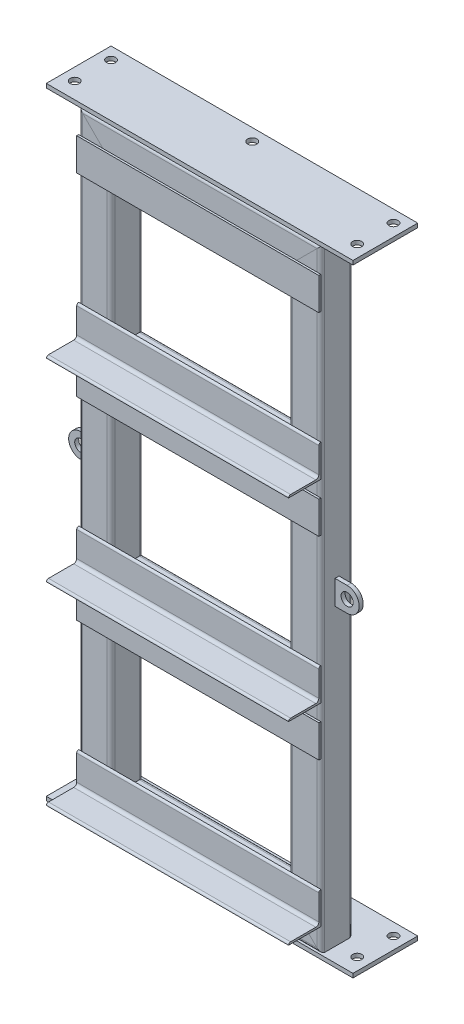
from build123d import *

# Parameters (mm, degrees)
STRUCTURAL_MEMBER1_DEPTH                = 951.321024484
STRUCTURAL_MEMBER1_DEPTH_BACK           = 36.921024484
STRUCTURAL_MEMBER1_2_DEPTH              = 404.042048969
STRUCTURAL_MEMBER1_3_DEPTH              = 988.242048969
STRUCTURAL_MEMBER1_4_DEPTH              = 404.042048969
STRUCTURAL_MEMBER1_5_DEPTH              = 332.2
STRUCTURAL_MEMBER1_6_DEPTH              = 332.2
SKETCH12_W                              = 482.6
SKETCH12_H                              = 101.865039743
BOSS_EXTRUDE1_DEPTH                     = 6.35
F_9_16_0_5625_DIAMETER_HOLE1_AT_2_COUNT = 2
F_9_16_0_5625_DIAMETER_HOLE1_AT_2_PITCH = 57.15
F_9_16_0_5625_DIAMETER_HOLE1_AT_3_COUNT = 2
F_9_16_0_5625_DIAMETER_HOLE1_AT_3_PITCH = 448.15886971
F_9_16_0_5625_DIAMETER_HOLE1_AT_4_COUNT = 2
F_9_16_0_5625_DIAMETER_HOLE1_AT_4_PITCH = 444.5
F_9_16_0_5625_DIAMETER_HOLE1_AT_5_COUNT = 2
F_9_16_0_5625_DIAMETER_HOLE1_AT_5_PITCH = 222.25
STRUCTURAL_MEMBER2_DEPTH                = 381
SKETCH142_W                             = 3.175
SKETCH142_H                             = 50.8
BOSS_EXTRUDE2_DEPTH                     = 381
LPATTERN1_COUNT                         = 3
LPATTERN1_PITCH                         = 304.8
SKETCH144_R                             = 9.525
BOSS_EXTRUDE3_DEPTH                     = 3.175


with BuildPart() as part:
    # Sketch11 → Structural Member1 (new, two sides)
    with BuildSketch(Plane(origin=(-165.1, -457.2, 0), x_dir=(-1, 0, 0), z_dir=(0, 1, 0))) as structural_member1_sk:
        with BuildLine():
            Line((-19.304, -25.4), (19.304, -25.4))
            ThreePointArc((19.304, -25.4), (23.614522938, -23.614522938), (25.4, -19.304))
            Line((25.4, -19.304), (25.4, 19.304))
            ThreePointArc((25.4, 19.304), (23.614522938, 23.614522938), (19.304, 25.4))
            Line((19.304, 25.4), (-19.304, 25.4))
            ThreePointArc((-19.304, 25.4), (-23.614522938, 23.614522938), (-25.4, 19.304))
            Line((-25.4, 19.304), (-25.4, -19.304))
            ThreePointArc((-25.4, -19.304), (-23.614522938, -23.614522938), (-19.304, -25.4))
        make_face()
        with BuildLine():
            Line((-19.304, -22.352), (19.304, -22.352))
            ThreePointArc((19.304, -22.352), (21.459261469, -21.459261469), (22.352, -19.304))
            Line((22.352, -19.304), (22.352, 19.304))
            ThreePointArc((22.352, 19.304), (21.459261469, 21.459261469), (19.304, 22.352))
            Line((19.304, 22.352), (-19.304, 22.352))
            ThreePointArc((-19.304, 22.352), (-21.459261469, 21.459261469), (-22.352, 19.304))
            Line((-22.352, 19.304), (-22.352, -19.304))
            ThreePointArc((-22.352, -19.304), (-21.459261469, -21.459261469), (-19.304, -22.352))
        make_face(mode=Mode.SUBTRACT)
    extrude(amount=STRUCTURAL_MEMBER1_DEPTH)
    extrude(structural_member1_sk.sketch, amount=-STRUCTURAL_MEMBER1_DEPTH_BACK)

    # Structural Member1 mitre 1
    split(bisect_by=Plane(origin=(-165.1, -457.2, 0), x_dir=(-0.707106781, -0.707106781, 0), z_dir=(-0.707106781, 0.707106781, 0)), keep=Keep.TOP)

    # Structural Member1 mitre 2
    split(bisect_by=Plane(origin=(-165.1, 457.2, 0), x_dir=(0.707106781, -0.707106781, 0), z_dir=(-0.707106781, -0.707106781, 0)), keep=Keep.TOP)


with BuildPart() as body_2:
    # Sketch11 on segment 2 (carried to segment 2) → Structural Member1 2 (new body)
    with BuildSketch(Plane(origin=(-202.021024484, 457.2, 0), x_dir=(0, 1, 0), z_dir=(1, 0, 0))):
        with BuildLine():
            Line((-19.304, -25.4), (19.304, -25.4))
            ThreePointArc((19.304, -25.4), (23.614522938, -23.614522938), (25.4, -19.304))
            Line((25.4, -19.304), (25.4, 19.304))
            ThreePointArc((25.4, 19.304), (23.614522938, 23.614522938), (19.304, 25.4))
            Line((19.304, 25.4), (-19.304, 25.4))
            ThreePointArc((-19.304, 25.4), (-23.614522938, 23.614522938), (-25.4, 19.304))
            Line((-25.4, 19.304), (-25.4, -19.304))
            ThreePointArc((-25.4, -19.304), (-23.614522938, -23.614522938), (-19.304, -25.4))
        make_face()
        with BuildLine():
            Line((-19.304, -22.352), (19.304, -22.352))
            ThreePointArc((19.304, -22.352), (21.459261469, -21.459261469), (22.352, -19.304))
            Line((22.352, -19.304), (22.352, 19.304))
            ThreePointArc((22.352, 19.304), (21.459261469, 21.459261469), (19.304, 22.352))
            Line((19.304, 22.352), (-19.304, 22.352))
            ThreePointArc((-19.304, 22.352), (-21.459261469, 21.459261469), (-22.352, 19.304))
            Line((-22.352, 19.304), (-22.352, -19.304))
            ThreePointArc((-22.352, -19.304), (-21.459261469, -21.459261469), (-19.304, -22.352))
        make_face(mode=Mode.SUBTRACT)
    extrude(amount=STRUCTURAL_MEMBER1_2_DEPTH)

    # Structural Member1 2 mitre 1
    split(bisect_by=Plane(origin=(165.1, 457.2, 0), x_dir=(-0.707106781, -0.707106781, 0), z_dir=(-0.707106781, 0.707106781, 0)), keep=Keep.TOP)

    # Structural Member1 2 mitre 2
    split(bisect_by=Plane(origin=(-165.1, 457.2, 0), x_dir=(-0.707106781, 0.707106781, 0), z_dir=(0.707106781, 0.707106781, 0)), keep=Keep.TOP)


with BuildPart() as body_3:
    # Sketch11 on segment 3 (carried to segment 3) → Structural Member1 3 (new body)
    with BuildSketch(Plane(origin=(165.1, 494.121024484, 0), x_dir=(1, 0, 0), z_dir=(0, -1, 0))):
        with BuildLine():
            Line((-19.304, -25.4), (19.304, -25.4))
            ThreePointArc((19.304, -25.4), (23.614522938, -23.614522938), (25.4, -19.304))
            Line((25.4, -19.304), (25.4, 19.304))
            ThreePointArc((25.4, 19.304), (23.614522938, 23.614522938), (19.304, 25.4))
            Line((19.304, 25.4), (-19.304, 25.4))
            ThreePointArc((-19.304, 25.4), (-23.614522938, 23.614522938), (-25.4, 19.304))
            Line((-25.4, 19.304), (-25.4, -19.304))
            ThreePointArc((-25.4, -19.304), (-23.614522938, -23.614522938), (-19.304, -25.4))
        make_face()
        with BuildLine():
            Line((-19.304, -22.352), (19.304, -22.352))
            ThreePointArc((19.304, -22.352), (21.459261469, -21.459261469), (22.352, -19.304))
            Line((22.352, -19.304), (22.352, 19.304))
            ThreePointArc((22.352, 19.304), (21.459261469, 21.459261469), (19.304, 22.352))
            Line((19.304, 22.352), (-19.304, 22.352))
            ThreePointArc((-19.304, 22.352), (-21.459261469, 21.459261469), (-22.352, 19.304))
            Line((-22.352, 19.304), (-22.352, -19.304))
            ThreePointArc((-22.352, -19.304), (-21.459261469, -21.459261469), (-19.304, -22.352))
        make_face(mode=Mode.SUBTRACT)
    extrude(amount=STRUCTURAL_MEMBER1_3_DEPTH)

    # Structural Member1 3 mitre 1
    split(bisect_by=Plane(origin=(165.1, -457.2, 0), x_dir=(-0.707106781, 0.707106781, 0), z_dir=(0.707106781, 0.707106781, 0)), keep=Keep.TOP)

    # Structural Member1 3 mitre 2
    split(bisect_by=Plane(origin=(165.1, 457.2, 0), x_dir=(0.707106781, 0.707106781, 0), z_dir=(0.707106781, -0.707106781, 0)), keep=Keep.TOP)


with BuildPart() as body_4:
    # Sketch11 on segment 4 (carried to segment 4) → Structural Member1 4 (new body)
    with BuildSketch(Plane(origin=(202.021024484, -457.2, 0), x_dir=(0, -1, 0), z_dir=(-1, 0, 0))):
        with BuildLine():
            Line((-19.304, -25.4), (19.304, -25.4))
            ThreePointArc((19.304, -25.4), (23.614522938, -23.614522938), (25.4, -19.304))
            Line((25.4, -19.304), (25.4, 19.304))
            ThreePointArc((25.4, 19.304), (23.614522938, 23.614522938), (19.304, 25.4))
            Line((19.304, 25.4), (-19.304, 25.4))
            ThreePointArc((-19.304, 25.4), (-23.614522938, 23.614522938), (-25.4, 19.304))
            Line((-25.4, 19.304), (-25.4, -19.304))
            ThreePointArc((-25.4, -19.304), (-23.614522938, -23.614522938), (-19.304, -25.4))
        make_face()
        with BuildLine():
            Line((-19.304, -22.352), (19.304, -22.352))
            ThreePointArc((19.304, -22.352), (21.459261469, -21.459261469), (22.352, -19.304))
            Line((22.352, -19.304), (22.352, 19.304))
            ThreePointArc((22.352, 19.304), (21.459261469, 21.459261469), (19.304, 22.352))
            Line((19.304, 22.352), (-19.304, 22.352))
            ThreePointArc((-19.304, 22.352), (-21.459261469, 21.459261469), (-22.352, 19.304))
            Line((-22.352, 19.304), (-22.352, -19.304))
            ThreePointArc((-22.352, -19.304), (-21.459261469, -21.459261469), (-19.304, -22.352))
        make_face(mode=Mode.SUBTRACT)
    extrude(amount=STRUCTURAL_MEMBER1_4_DEPTH)

    # Structural Member1 4 mitre 1
    split(bisect_by=Plane(origin=(165.1, -457.2, 0), x_dir=(0.707106781, -0.707106781, 0), z_dir=(-0.707106781, -0.707106781, 0)), keep=Keep.TOP)

    # Structural Member1 4 mitre 2
    split(bisect_by=Plane(origin=(-165.1, -457.2, 0), x_dir=(0.707106781, 0.707106781, 0), z_dir=(0.707106781, -0.707106781, 0)), keep=Keep.TOP)


with BuildPart() as body_5:
    # Sketch11 on segment 5 (carried to segment 5) → Structural Member1 5 (new body)
    with BuildSketch(Plane(origin=(-166.1, 152.4, 0), x_dir=(0, 1, 0), z_dir=(1, 0, 0))):
        with BuildLine():
            Line((-19.304, -25.4), (19.304, -25.4))
            ThreePointArc((19.304, -25.4), (23.614522938, -23.614522938), (25.4, -19.304))
            Line((25.4, -19.304), (25.4, 19.304))
            ThreePointArc((25.4, 19.304), (23.614522938, 23.614522938), (19.304, 25.4))
            Line((19.304, 25.4), (-19.304, 25.4))
            ThreePointArc((-19.304, 25.4), (-23.614522938, 23.614522938), (-25.4, 19.304))
            Line((-25.4, 19.304), (-25.4, -19.304))
            ThreePointArc((-25.4, -19.304), (-23.614522938, -23.614522938), (-19.304, -25.4))
        make_face()
        with BuildLine():
            Line((-19.304, -22.352), (19.304, -22.352))
            ThreePointArc((19.304, -22.352), (21.459261469, -21.459261469), (22.352, -19.304))
            Line((22.352, -19.304), (22.352, 19.304))
            ThreePointArc((22.352, 19.304), (21.459261469, 21.459261469), (19.304, 22.352))
            Line((19.304, 22.352), (-19.304, 22.352))
            ThreePointArc((-19.304, 22.352), (-21.459261469, 21.459261469), (-22.352, 19.304))
            Line((-22.352, 19.304), (-22.352, -19.304))
            ThreePointArc((-22.352, -19.304), (-21.459261469, -21.459261469), (-19.304, -22.352))
        make_face(mode=Mode.SUBTRACT)
    extrude(amount=STRUCTURAL_MEMBER1_5_DEPTH)

    # Structural Member1 5 mitre 1
    split(bisect_by=Plane(origin=(-139.7, 152.4, 0), x_dir=(0, 1, 0), z_dir=(1, 0, 0)), keep=Keep.TOP)

    # Structural Member1 5 mitre 2
    split(bisect_by=Plane(origin=(139.7, 152.4, 0), x_dir=(0, -1, 0), z_dir=(-1, 0, 0)), keep=Keep.TOP)


with BuildPart() as body_6:
    # Sketch11 on segment 6 (carried to segment 6) → Structural Member1 6 (new body)
    with BuildSketch(Plane(origin=(-166.1, -152.4, 0), x_dir=(0, 1, 0), z_dir=(1, 0, 0))):
        with BuildLine():
            Line((-19.304, -25.4), (19.304, -25.4))
            ThreePointArc((19.304, -25.4), (23.614522938, -23.614522938), (25.4, -19.304))
            Line((25.4, -19.304), (25.4, 19.304))
            ThreePointArc((25.4, 19.304), (23.614522938, 23.614522938), (19.304, 25.4))
            Line((19.304, 25.4), (-19.304, 25.4))
            ThreePointArc((-19.304, 25.4), (-23.614522938, 23.614522938), (-25.4, 19.304))
            Line((-25.4, 19.304), (-25.4, -19.304))
            ThreePointArc((-25.4, -19.304), (-23.614522938, -23.614522938), (-19.304, -25.4))
        make_face()
        with BuildLine():
            Line((-19.304, -22.352), (19.304, -22.352))
            ThreePointArc((19.304, -22.352), (21.459261469, -21.459261469), (22.352, -19.304))
            Line((22.352, -19.304), (22.352, 19.304))
            ThreePointArc((22.352, 19.304), (21.459261469, 21.459261469), (19.304, 22.352))
            Line((19.304, 22.352), (-19.304, 22.352))
            ThreePointArc((-19.304, 22.352), (-21.459261469, 21.459261469), (-22.352, 19.304))
            Line((-22.352, 19.304), (-22.352, -19.304))
            ThreePointArc((-22.352, -19.304), (-21.459261469, -21.459261469), (-19.304, -22.352))
        make_face(mode=Mode.SUBTRACT)
    extrude(amount=STRUCTURAL_MEMBER1_6_DEPTH)

    # Structural Member1 6 mitre 1
    split(bisect_by=Plane(origin=(-139.7, -152.4, 0), x_dir=(0, 1, 0), z_dir=(1, 0, 0)), keep=Keep.TOP)

    # Structural Member1 6 mitre 2
    split(bisect_by=Plane(origin=(139.7, -152.4, 0), x_dir=(0, -1, 0), z_dir=(-1, 0, 0)), keep=Keep.TOP)


with BuildPart() as body_7:
    # Sketch12 → Boss-Extrude1 (new body)
    with BuildSketch(Plane(origin=(0, 482.6, 0), x_dir=(1, 0, 0), z_dir=(0, 1, 0))):
        with Locations((0, 25.267480129)):
            Rectangle(SKETCH12_W, SKETCH12_H)
    extrude(amount=BOSS_EXTRUDE1_DEPTH)

    # Sketch13 → 9/16 (0.5625) Diameter Hole1 (revolve, cut)
    with BuildSketch(Plane(origin=(-222.25, 488.95, -57.15), x_dir=(0, 0, 1), z_dir=(1, 0, 0))):
        Polygon((0, 0), (0, 85.318398047), (7.14375, 81.026), (7.14375, 0), align=None)
    f_9_16_0_5625_diameter_hole1 = revolve(axis=Axis((-222.25, 495.3, -57.15), (0, -1, 0)), mode=Mode.SUBTRACT)

    # 9/16 (0.5625) Diameter Hole1 at 2: 9/16 (0.5625) Diameter Hole1 ×2
    with Locations(*[(0, 0, i * F_9_16_0_5625_DIAMETER_HOLE1_AT_2_PITCH) for i in range(1, F_9_16_0_5625_DIAMETER_HOLE1_AT_2_COUNT)]):
        add(f_9_16_0_5625_diameter_hole1, mode=Mode.SUBTRACT)

    # 9/16 (0.5625) Diameter Hole1 at 3: 9/16 (0.5625) Diameter Hole1 ×2
    with Locations(*[Vector(0.9918357753074261, 0, 0.12752174253952614) * (i * F_9_16_0_5625_DIAMETER_HOLE1_AT_3_PITCH) for i in range(1, F_9_16_0_5625_DIAMETER_HOLE1_AT_3_COUNT)]):
        add(f_9_16_0_5625_diameter_hole1, mode=Mode.SUBTRACT)

    # 9/16 (0.5625) Diameter Hole1 at 4: 9/16 (0.5625) Diameter Hole1 ×2
    with Locations(*[(i * F_9_16_0_5625_DIAMETER_HOLE1_AT_4_PITCH, 0, 0) for i in range(1, F_9_16_0_5625_DIAMETER_HOLE1_AT_4_COUNT)]):
        add(f_9_16_0_5625_diameter_hole1, mode=Mode.SUBTRACT)

    # 9/16 (0.5625) Diameter Hole1 at 5: 9/16 (0.5625) Diameter Hole1 ×2
    with Locations(*[(i * F_9_16_0_5625_DIAMETER_HOLE1_AT_5_PITCH, 0, 0) for i in range(1, F_9_16_0_5625_DIAMETER_HOLE1_AT_5_COUNT)]):
        add(f_9_16_0_5625_diameter_hole1, mode=Mode.SUBTRACT)


with BuildPart() as body_8:
    # Mirror1: mirrored copy
    add(body_7.part.mirror(Plane.ZX))


with BuildPart() as body_9:
    # Sketch141 → Structural Member2 (new body)
    with BuildSketch(Plane(origin=(-190.5, 165.1, 25.4), x_dir=(0, 1, 0), z_dir=(1, 0, 0))):
        with BuildLine():
            Line((0, 0), (0, 50.8))
            Line((0, 50.8), (0.00508, 50.8))
            ThreePointArc((0.00508, 50.8), (2.246551928, 49.871551928), (3.175, 47.63008))
            Line((3.175, 47.63008), (3.175, 7.9375))
            ThreePointArc((3.175, 7.9375), (4.569903955, 4.569903955), (7.9375, 3.175))
            Line((7.9375, 3.175), (47.63008, 3.175))
            ThreePointArc((47.63008, 3.175), (49.871551928, 2.246551928), (50.8, 0.00508))
            Line((50.8, 0.00508), (50.8, 0))
            Line((50.8, 0), (0, 0))
        make_face()
    extrude(amount=STRUCTURAL_MEMBER2_DEPTH)


with BuildPart() as body_10:
    # Sketch142 → Boss-Extrude2 (new body)
    with BuildSketch(Plane(origin=(190.5, 0, 0), x_dir=(0, 0, -1), z_dir=(1, 0, 0))):
        with Locations((-26.9875, 419.1)):
            Rectangle(SKETCH142_W, SKETCH142_H)
    extrude(amount=-BOSS_EXTRUDE2_DEPTH)


with BuildPart() as lpattern1_1:
    # LPattern1: pattern copy
    add(body_10.part.moved(Location(Vector(0, -1, 0) * (1 * LPATTERN1_PITCH))))


with BuildPart() as lpattern1_2:
    # LPattern1: pattern copy
    add(body_10.part.moved(Location(Vector(0, -1, 0) * (2 * LPATTERN1_PITCH))))


with BuildPart() as lpattern1_3:
    # LPattern1: pattern copy
    add(body_9.part.moved(Location(Vector(0, -1, 0) * (1 * LPATTERN1_PITCH))))


with BuildPart() as lpattern1_4:
    # LPattern1: pattern copy
    add(body_9.part.moved(Location(Vector(0, -1, 0) * (2 * LPATTERN1_PITCH))))


with BuildPart() as body_15:
    # Sketch144 → Boss-Extrude3 (new, symmetric)
    with BuildSketch(Plane.XY):
        with BuildLine():
            Line((209.55, 19.05), (190.5, 19.05))
            Line((190.5, 19.05), (190.5, -19.05))
            Line((190.5, -19.05), (209.55, -19.05))
            ThreePointArc((209.55, -19.05), (228.6, 0), (209.55, 19.05))
        make_face()
        with Locations((209.55, 0)):
            Circle(SKETCH144_R, mode=Mode.SUBTRACT)
    extrude(amount=BOSS_EXTRUDE3_DEPTH, both=True)


with BuildPart() as body_16:
    # Mirror3: mirrored copy
    add(body_15.part.mirror(Plane(origin=(0, 0, 0), x_dir=(0, 0, 1), z_dir=(1, 0, 0))))


solid = Compound([part.part, body_2.part, body_3.part, body_4.part, body_5.part, body_6.part, body_7.part, body_8.part, body_9.part, body_10.part, lpattern1_1.part, lpattern1_2.part, lpattern1_3.part, lpattern1_4.part, body_15.part, body_16.part])
